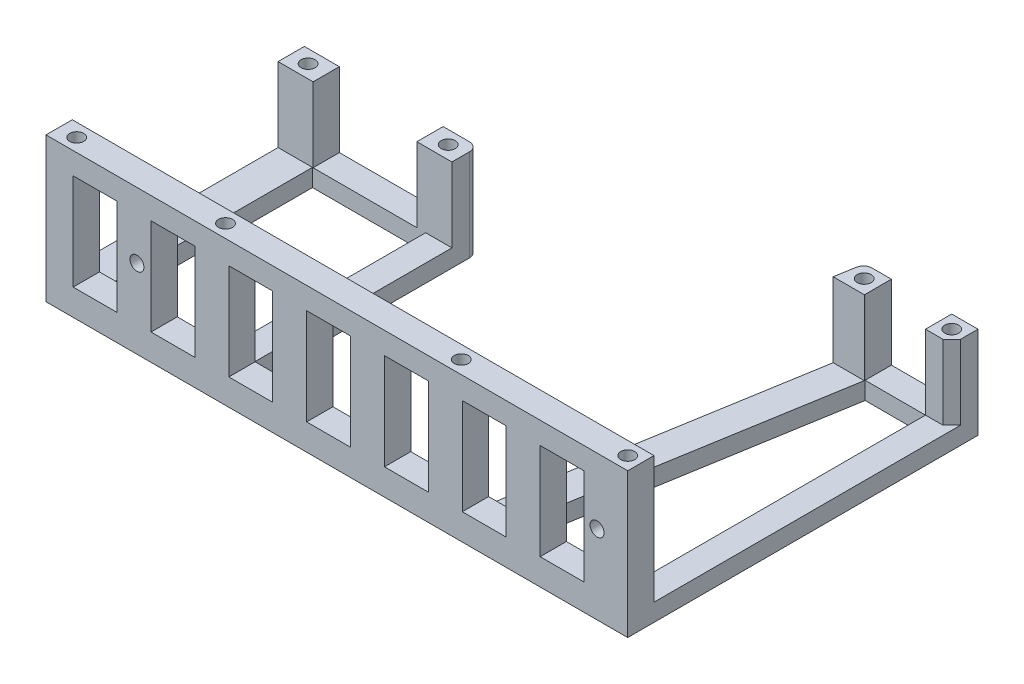
from build123d import *

# Parameters (mm, degrees)
SKETCH_1_R          = 1.6
SKETCH_1_W          = 25.85
SKETCH_1_H          = 47
EXTRUDE_1_DEPTH     = 4
SKETCH_2_W          = 8
SKETCH_2_H          = 6
SKETCH_2_R          = 1.6
EXTRUDE_2_DEPTH     = 17
FILLET_1_R          = 2
SKETCH_3_W          = 132.85
SKETCH_3_H          = 6
EXTRUDE_3_DEPTH     = 29
SKETCH_4_W          = 10
SKETCH_4_H          = 22
CUT_EXTRUDE_1_DEPTH = 7
SKETCH_5_R          = 1.6
CUT_EXTRUDE_2_DEPTH = 34
SKETCH_6_R          = 1.6
CUT_EXTRUDE_3_DEPTH = 7


with BuildPart() as part:
    # Эскиз1 → Бобышка-Вытянуть1 (new body)
    with BuildSketch(Plane(origin=(0, 0, 0), x_dir=(1, 0, 0), z_dir=(0, 1, 0))):
        Polygon((66, 24), (66, -56), (-66.85, -56), (-66.85, 3), (-59.15, 3), (-34.85, 3), (-27.15, 3), (-27.15, -50), (27.704212942, -50), (40.133263836, 24), (60, 24), align=None)
        with Locations((63, 21)):
            Circle(SKETCH_1_R, mode=Mode.SUBTRACT)
        with Locations((-63, 0)):
            Circle(SKETCH_1_R, mode=Mode.SUBTRACT)
        with Locations((-31, 0)):
            Circle(SKETCH_1_R, mode=Mode.SUBTRACT)
        with Locations((43, 21)):
            Circle(SKETCH_1_R, mode=Mode.SUBTRACT)
        with Locations((-46.075, -26.5)):
            Rectangle(SKETCH_1_W, SKETCH_1_H, mode=Mode.SUBTRACT)
        Polygon((60, 18), (60, -50), (34.802263374, -50), (46.223553385, 18), align=None, mode=Mode.SUBTRACT)
    extrude(amount=EXTRUDE_1_DEPTH)

    # Эскиз2 → Бобышка-Вытянуть2 (add)
    with BuildSketch(Plane.XZ.offset(-4)):
        with Locations((-62.85, 0)):
            Rectangle(SKETCH_2_W, SKETCH_2_H)
        with Locations((-63, 0)):
            Circle(SKETCH_2_R, mode=Mode.SUBTRACT)
        Polygon((66, -20), (66, -24), (60, -24), (60, -18), (64, -18), align=None)
        with Locations((63, -21)):
            Circle(SKETCH_2_R, mode=Mode.SUBTRACT)
        with Locations((-31.15, 0)):
            Rectangle(SKETCH_2_W, SKETCH_2_H)
        with Locations((-31, 0)):
            Circle(SKETCH_2_R, mode=Mode.SUBTRACT)
        Polygon((46.223553385, -18), (46.223553385, -24), (40.133263836, -24), (39.097062378, -17.830670696), (46.195112811, -17.830670696), align=None)
        with Locations((43, -21)):
            Circle(SKETCH_2_R, mode=Mode.SUBTRACT)
    extrude(amount=-EXTRUDE_2_DEPTH)

    # Скругление1
    fillet_1_edges = [part.edges().sort_by_distance(p)[0] for p in [
        (-27.15, 10.5, -3),
        (40.133263836, 10.5, -24),
    ]]
    fillet(fillet_1_edges, radius=FILLET_1_R)

    # Эскиз3 → Бобышка-Вытянуть3 (add)
    with BuildSketch(Plane.XZ.offset(-4)):
        with Locations((-0.425, 53)):
            Rectangle(SKETCH_3_W, SKETCH_3_H)
    extrude(amount=-EXTRUDE_3_DEPTH)

    # Эскиз4 → Вырез-Вытянуть1 (cut, through all)
    with BuildSketch(Plane(origin=(0, 0, 50), x_dir=(-1, 0, 0), z_dir=(0, 0, -1))):
        with Locations((20.095331259, 17)):
            Rectangle(SKETCH_4_W, SKETCH_4_H)
        with Locations((2.321498445, 17)):
            Rectangle(SKETCH_4_W, SKETCH_4_H)
        with Locations((-15.45233437, 17)):
            Rectangle(SKETCH_4_W, SKETCH_4_H)
        with Locations((-33.226167185, 17)):
            Rectangle(SKETCH_4_W, SKETCH_4_H)
        with Locations((-51, 17)):
            Rectangle(SKETCH_4_W, SKETCH_4_H)
        with Locations((37.869164074, 17)):
            Rectangle(SKETCH_4_W, SKETCH_4_H)
        with Locations((55.642996889, 17)):
            Rectangle(SKETCH_4_W, SKETCH_4_H)
    extrude(amount=-CUT_EXTRUDE_1_DEPTH, mode=Mode.SUBTRACT)

    # Эскиз5 → Вырез-Вытянуть2 (cut, through all)
    with BuildSketch(Plane(origin=(0, 0, 0), x_dir=(1, 0, 0), z_dir=(0, 1, 0))):
        with Locations((-62.85, -53)):
            Circle(SKETCH_5_R)
        with Locations((-28.85, -53)):
            Circle(SKETCH_5_R)
        with Locations((63, -53)):
            Circle(SKETCH_5_R)
        with Locations((25, -53)):
            Circle(SKETCH_5_R)
    extrude(amount=CUT_EXTRUDE_2_DEPTH, mode=Mode.SUBTRACT)

    # Эскиз6 → Вырез-Вытянуть3 (cut, through all)
    with BuildSketch(Plane(origin=(0, 0, 50), x_dir=(-1, 0, 0), z_dir=(0, 0, -1))):
        with Locations((46.08, 18)):
            Circle(SKETCH_6_R)
        with Locations((-59, 18)):
            Circle(SKETCH_6_R)
    extrude(amount=-CUT_EXTRUDE_3_DEPTH, mode=Mode.SUBTRACT)


solid = part.part
